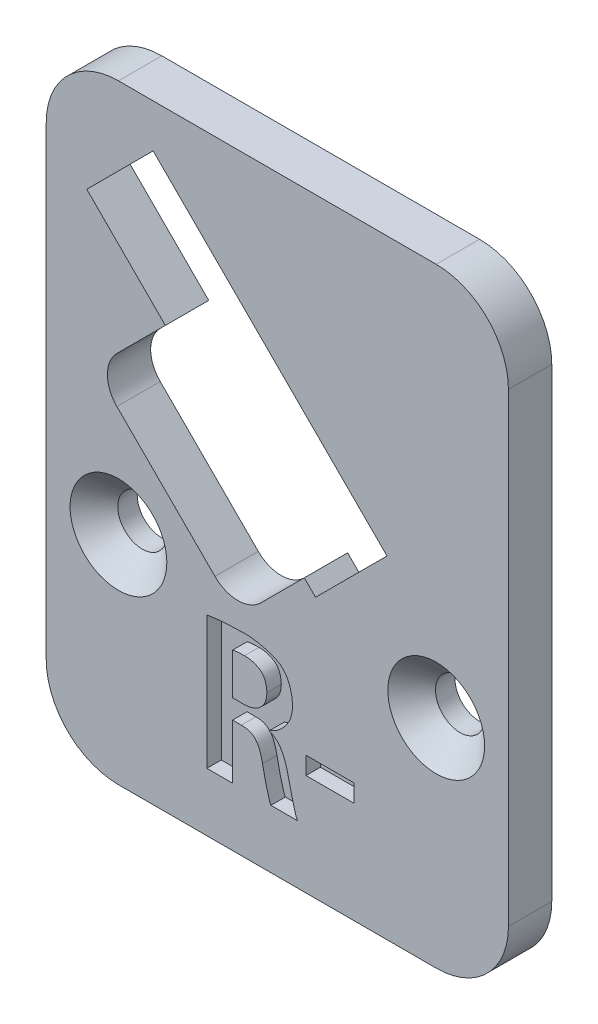
from build123d import *

# Parameters (mm, degrees)
SKETCH2_W                                           = 32
SKETCH2_H                                           = 42.204432033
BOSS_EXTRUDE2_DEPTH                                 = 3
FILLET1_R                                           = 5
SKETCH3_W                                           = 3.336226562
SKETCH3_H                                           = 1.222113554
CUT_EXTRUDE1_DEPTH                                  = 1
CSK_FOR_M3_COUNTERSUNK_FLAT_HEAD_SCREW1_D           = 3.4
CSK_FOR_M3_COUNTERSUNK_FLAT_HEAD_SCREW1_DEPTH       = 20
CSK_FOR_M3_COUNTERSUNK_FLAT_HEAD_SCREW1_CSINK_D     = 6.7
CSK_FOR_M3_COUNTERSUNK_FLAT_HEAD_SCREW1_CSINK_ANGLE = 90
CSK_FOR_M3_COUNTERSUNK_FLAT_HEAD_SCREW1_TIP         = 1.021463052
CUT_EXTRUDE3_DEPTH                                  = 10


with BuildPart() as part:
    # Sketch2 → Boss-Extrude2 (new body)
    with BuildSketch(Plane.XY):
        with Locations((-46.5, -1.397783984)):
            Rectangle(SKETCH2_W, SKETCH2_H)
    extrude(amount=BOSS_EXTRUDE2_DEPTH)

    # Fillet1
    fillet1_edges = [part.edges().sort_by_distance(p)[0] for p in [
        (-62.5, 19.704432033, 1.5),
        (-30.5, 19.704432033, 1.5),
        (-30.5, -22.5, 1.5),
        (-62.5, -22.5, 1.5),
    ]]
    fillet(fillet1_edges, radius=FILLET1_R)

    # Sketch3 → Cut-Extrude1 (cut)
    with BuildSketch(Plane.XY.offset(3)):
        with BuildLine():
            Line((-51.381425439, -18.458875061), (-49.597421385, -18.458875061))
            Line((-49.597421385, -18.458875061), (-49.597421385, -14.672122679))
            Line((-49.597421385, -14.672122679), (-48.991938415, -14.672122679))
            add(Edge.make_bspline(
                [(-48.991938415, -14.672122679), (-48.942050564, -14.6725211), (-48.843919084, -14.673304811), (-48.701136712, -14.687536776), (-48.566178681, -14.711269605), (-48.441222715, -14.74890661), (-48.32427753, -14.795186794), (-48.218202264, -14.856795477), (-48.11890245, -14.926037335), (-48.029787183, -15.010644116), (-47.94865002, -15.109304476), (-47.870329282, -15.22163632), (-47.801359571, -15.353586411), (-47.734046558, -15.500135947), (-47.675917518, -15.664809001), (-47.618382932, -15.843956856), (-47.570508607, -16.041536599), (-47.542007813, -16.179191645), (-47.527206071, -16.25068209)],
                knots=[0, 0, 0, 0, 0.000149599, 0.000294267, 0.000429961, 0.000559969, 0.000685182, 0.000806276, 0.000927115, 0.001047609, 0.001173509, 0.001309883, 0.001457588, 0.001619475, 0.001793345, 0.001981055, 0.002183769, 0.002402801, 0.002402801, 0.002402801, 0.002402801], degree=3))
            add(Edge.make_bspline(
                [(-47.527206071, -16.25068209), (-47.500027556, -16.387123246), (-47.447932519, -16.648649934), (-47.367799698, -17.023584407), (-47.286395279, -17.362673147), (-47.211369572, -17.666100231), (-47.134583702, -17.927379781), (-47.069987521, -18.146751884), (-47.009849282, -18.32008565), (-46.966417008, -18.417682148), (-46.947756493, -18.45961412)],
                knots=[0, 0, 0, 0, 0.000417367, 0.000799998, 0.001150089, 0.001463532, 0.001737527, 0.001966934, 0.002149658, 0.002287303, 0.002287303, 0.002287303, 0.002287303], degree=3))
            Line((-46.947756493, -18.45961412), (-45.111733669, -18.458875061))
            add(Edge.make_bspline(
                [(-45.111733669, -18.458875061), (-45.136394395, -18.402686862), (-45.192836553, -18.274086301), (-45.264632108, -18.048232695), (-45.345858267, -17.770288113), (-45.428958388, -17.444111213), (-45.51591734, -17.08294144), (-45.610026609, -16.699954349), (-45.704155867, -16.299301278), (-45.768362179, -16.026508782), (-45.80114869, -15.887209172)],
                knots=[0, 0, 0, 0, 0.000183977, 0.000421076, 0.000710029, 0.001052867, 0.00143062, 0.001824558, 0.002235981, 0.002665299, 0.002665299, 0.002665299, 0.002665299], degree=3))
            add(Edge.make_bspline(
                [(-45.80114869, -15.887209172), (-45.828641018, -15.773168942), (-45.881780404, -15.5527428), (-45.987295673, -15.242137194), (-46.108403792, -14.961961493), (-46.246109756, -14.712628496), (-46.405457942, -14.494327391), (-46.588613385, -14.309294243), (-46.799272936, -14.160659908), (-46.954100619, -14.089741414), (-47.032040068, -14.054041414)],
                knots=[0, 0, 0, 0, 0.000351778, 0.000679945, 0.00098268, 0.001266475, 0.001532679, 0.001790935, 0.002044255, 0.002301038, 0.002301038, 0.002301038, 0.002301038], degree=3))
            Line((-47.032040068, -14.054041414), (-47.030656262, -14.017001018))
            add(Edge.make_bspline(
                [(-47.030656262, -14.017001018), (-46.922273974, -13.970005767), (-46.706005829, -13.876230519), (-46.411856808, -13.676157256), (-46.14181559, -13.438863882), (-45.942211161, -13.208200023), (-45.802357006, -13.003332314), (-45.709339658, -12.840203194), (-45.629535439, -12.668874791), (-45.565066724, -12.488727388), (-45.51180506, -12.300576236), (-45.473637881, -12.103222096), (-45.448546386, -11.89781805), (-45.443663093, -11.757970901), (-45.441187588, -11.68707768)],
                knots=[0, 0, 0, 0, 0.000353722, 0.000705825, 0.001061629, 0.00143016, 0.001617179, 0.001805135, 0.001992894, 0.002183416, 0.002378543, 0.002578963, 0.00278587, 0.002998596, 0.002998596, 0.002998596, 0.002998596], degree=3))
            add(Edge.make_bspline(
                [(-45.441187588, -11.68707768), (-45.446164978, -11.614412673), (-45.455946444, -11.471612893), (-45.485146081, -11.263842973), (-45.519750271, -11.065622921), (-45.563079094, -10.87842638), (-45.616257063, -10.701449), (-45.677340843, -10.534699828), (-45.747075442, -10.378252437), (-45.826987856, -10.232984263), (-45.914816466, -10.098344998), (-46.008796832, -9.971834439), (-46.116049062, -9.860313263), (-46.228017531, -9.754798011), (-46.351436153, -9.662838486), (-46.482253648, -9.578828028), (-46.62263241, -9.507518301), (-46.818699815, -9.427166253), (-47.06746288, -9.344888092), (-47.360362202, -9.252977107), (-47.648888658, -9.184061361), (-47.928465046, -9.126227189), (-48.201942503, -9.088865813), (-48.467771392, -9.061958609), (-48.727193986, -9.057551627), (-48.897426641, -9.065240143), (-48.981097742, -9.069019128)],
                knots=[0, 0, 0, 0, 0.000218439, 0.000429273, 0.000629045, 0.000821988, 0.00100531, 0.001183082, 0.001354416, 0.001518656, 0.001679866, 0.001836496, 0.001990536, 0.002143381, 0.002297551, 0.002451481, 0.002609328, 0.002769115, 0.003086745, 0.003395031, 0.003689736, 0.003976245, 0.004251139, 0.004517418, 0.004777346, 0.005028594, 0.005028594, 0.005028594, 0.005028594], degree=3))
            add(Edge.make_bspline(
                [(-48.981097742, -9.069019128), (-49.204750164, -9.07164849), (-49.641894612, -9.076787763), (-50.178628932, -9.112050461), (-50.585677154, -9.150113546), (-50.867868242, -9.181499683), (-51.131979771, -9.216172913), (-51.301297073, -9.243625216), (-51.383179632, -9.256901264)],
                knots=[0, 0, 0, 0, 0.000670904, 0.001311329, 0.001612901, 0.001897363, 0.00216308, 0.002411924, 0.002411924, 0.002411924, 0.002411924], degree=3))
            Line((-51.383179632, -9.256901264), (-51.381425439, -18.458875061))
        make_face()
        with BuildLine():
            add(Edge.make_bspline(
                [(-49.597421385, -10.475098321), (-49.553118884, -10.463741178), (-49.449324767, -10.437133094), (-49.26651153, -10.418528414), (-49.036966225, -10.403821129), (-48.868179272, -10.40361956), (-48.775656528, -10.403509067)],
                knots=[0, 0, 0, 0, 0.000137048, 0.000321084, 0.000549784, 0.00082724, 0.00082724, 0.00082724, 0.00082724], degree=3))
            add(Edge.make_bspline(
                [(-48.775656528, -10.403509067), (-48.688241346, -10.402981113), (-48.513173263, -10.40192377), (-48.25262374, -10.452443011), (-47.99710085, -10.54015698), (-47.790180436, -10.642172207), (-47.635138174, -10.749873331), (-47.531709547, -10.851803167), (-47.444125211, -10.972739958), (-47.368662464, -11.111515899), (-47.313363495, -11.270485036), (-47.266241854, -11.445599811), (-47.237372321, -11.640002112), (-47.229365771, -11.775957367), (-47.225189927, -11.846865291)],
                knots=[0, 0, 0, 0, 0.000261725, 0.000524161, 0.000791249, 0.001070808, 0.00121308, 0.001355871, 0.001504077, 0.001659631, 0.001827951, 0.00200768, 0.002203123, 0.002416175, 0.002416175, 0.002416175, 0.002416175], degree=3))
            add(Edge.make_bspline(
                [(-47.225189927, -11.846865291), (-47.227175329, -11.901954186), (-47.231054857, -12.009599393), (-47.252578328, -12.166460507), (-47.285644456, -12.315396112), (-47.332465946, -12.455901219), (-47.395176387, -12.587424294), (-47.470077536, -12.710240218), (-47.559607688, -12.823418468), (-47.659086339, -12.929228854), (-47.771771397, -13.023790308), (-47.894893734, -13.107175482), (-48.0305682, -13.175598565), (-48.175685207, -13.233265514), (-48.331962757, -13.279426838), (-48.49835821, -13.311908188), (-48.675604243, -13.333661231), (-48.79724634, -13.337439587), (-48.859940103, -13.339386933)],
                knots=[0, 0, 0, 0, 0.000165289, 0.000322979, 0.000474201, 0.000622458, 0.000766196, 0.000910448, 0.001053055, 0.001198372, 0.001345408, 0.001493457, 0.001643451, 0.001800288, 0.001961411, 0.002131526, 0.002308376, 0.002496463, 0.002496463, 0.002496463, 0.002496463], degree=3))
            Line((-48.859940103, -13.339386933), (-49.597421385, -13.33763274))
            Line((-49.597421385, -13.33763274), (-49.597421385, -10.475098321))
        make_face(mode=Mode.SUBTRACT)
        with Locations((-42.847712603, -14.847712603)):
            Rectangle(SKETCH3_W, SKETCH3_H)
    extrude(amount=-CUT_EXTRUDE1_DEPTH, mode=Mode.SUBTRACT)

    # CSK for M3 Countersunk Flat Head Screw1
    with Locations(Plane(origin=(-57.5, -7.5, 3), x_dir=(1, 0, 0), z_dir=(0, 0, 1))):
        with Locations((0, 0), (22, 0)):
            CounterSinkHole(CSK_FOR_M3_COUNTERSUNK_FLAT_HEAD_SCREW1_D / 2, CSK_FOR_M3_COUNTERSUNK_FLAT_HEAD_SCREW1_CSINK_D / 2, depth=CSK_FOR_M3_COUNTERSUNK_FLAT_HEAD_SCREW1_DEPTH, counter_sink_angle=CSK_FOR_M3_COUNTERSUNK_FLAT_HEAD_SCREW1_CSINK_ANGLE)
            with Locations((0, 0, -(CSK_FOR_M3_COUNTERSUNK_FLAT_HEAD_SCREW1_DEPTH + CSK_FOR_M3_COUNTERSUNK_FLAT_HEAD_SCREW1_TIP / 2))):  # 118° drill point
                Cone(0, CSK_FOR_M3_COUNTERSUNK_FLAT_HEAD_SCREW1_D / 2, CSK_FOR_M3_COUNTERSUNK_FLAT_HEAD_SCREW1_TIP, mode=Mode.SUBTRACT)

    # Sketch13 → Cut-Extrude3 (cut)
    with BuildSketch(Plane(origin=(0, 0, 0), x_dir=(-1, 0, 0), z_dir=(0, 0, -1))):
        with BuildLine():
            Line((55.099076528, 16.704432033), (59.695270606, 12.108237955))
            Line((59.695270606, 12.108237955), (54.250548391, 6.66351574))
            Line((54.250548391, 6.66351574), (57.609305602, 3.304758529))
            ThreePointArc((57.609305602, 3.304758529), (58.268315344, 1.713768272), (57.609305602, 0.122778014))
            Line((57.609305602, 0.122778014), (50.821080502, -6.665447085))
            ThreePointArc((50.821080502, -6.665447085), (49.230090245, -7.324456828), (47.639099987, -6.665447085))
            Line((47.639099987, -6.665447085), (44.633896167, -3.660243265))
            Line((44.633896167, -3.660243265), (43.856078708, -4.438060725))
            Line((43.856078708, -4.438060725), (43.325748622, -3.907730639))
            Line((43.325748622, -3.907730639), (38.906331239, 0.511686744))
            Line((38.906331239, 0.511686744), (40.709453531, 2.314809036))
            Line((40.709453531, 2.314809036), (47.921942699, 9.527298204))
            Line((47.921942699, 9.527298204), (55.099076528, 16.704432033))
        make_face()
    extrude(amount=-CUT_EXTRUDE3_DEPTH, mode=Mode.SUBTRACT)


solid = part.part
